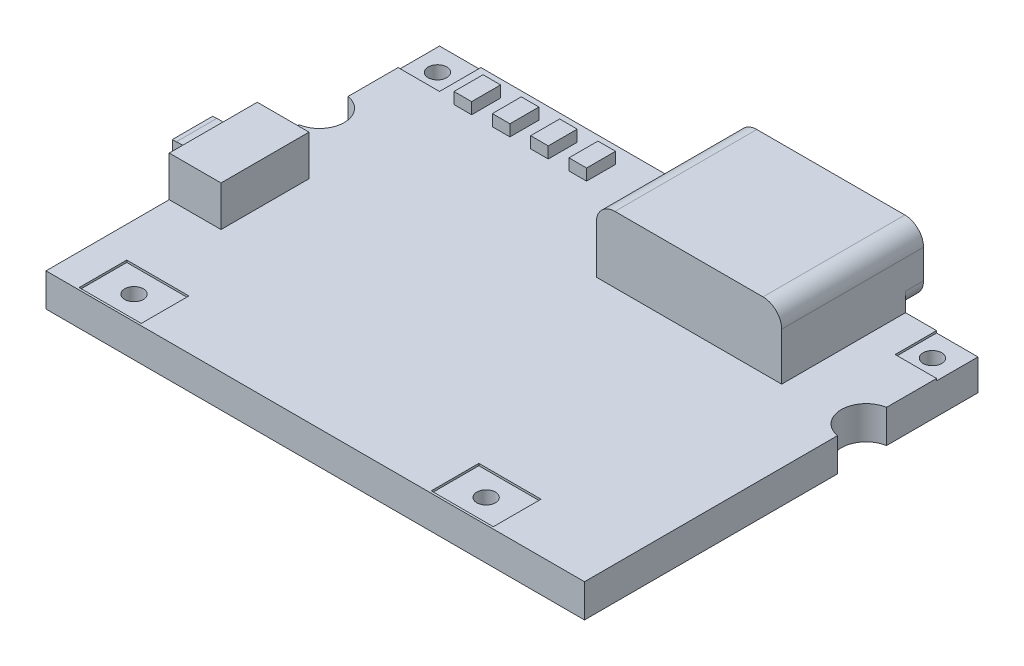
from build123d import *

# Parameters (mm, degrees)
SKETCH1_W           = 26
SKETCH1_H           = 19
BOSS_EXTRUDE1_DEPTH = 1.6
SKETCH2_W           = 8.95
SKETCH2_H           = 6.85
BOSS_EXTRUDE2_DEPTH = 3.2
SKETCH3_R           = 0.45
CUT_EXTRUDE1_DEPTH  = 17.934488478
SKETCH4_R           = 1.2
CUT_EXTRUDE2_DEPTH  = 17.934488478
SKETCH5_R           = 0.45
CUT_EXTRUDE3_DEPTH  = 17.934488478
SKETCH6_W           = 2
SKETCH6_H           = 2
SKETCH6_W_2         = 3
SKETCH6_H_2         = 2.3
CUT_EXTRUDE4_DEPTH  = 0.1
FILLET1_R           = 0.9
SKETCH8_W           = 2.5
SKETCH8_H           = 4.25
BOSS_EXTRUDE3_DEPTH = 1.95
SKETCH9_W           = 1.95
SKETCH9_H           = 0.95
BOSS_EXTRUDE4_DEPTH = 1
SKETCH10_W          = 0.85
SKETCH10_H          = 1.4
BOSS_EXTRUDE5_DEPTH = 0.55
LPATTERN1_COUNT     = 4
LPATTERN1_PITCH     = 1.85
SKETCH11_W          = 0.2
SKETCH11_H          = 1.95
CUT_EXTRUDE5_DEPTH  = 0.01


with BuildPart() as part:
    # Sketch1 → Boss-Extrude1 (new body)
    with BuildSketch(Plane(origin=(0, 0, 0), x_dir=(1, 0, 0), z_dir=(0, 1, 0))):
        Rectangle(SKETCH1_W, SKETCH1_H)
    extrude(amount=BOSS_EXTRUDE1_DEPTH)

    # Sketch2 → Boss-Extrude2 (add)
    with BuildSketch(Plane(origin=(0, 1.6, 0), x_dir=(1, 0, 0), z_dir=(0, 1, 0))):
        with Locations((5.025, 6.945)):
            Rectangle(SKETCH2_W, SKETCH2_H)
    extrude(amount=BOSS_EXTRUDE2_DEPTH)

    # Sketch3 → Cut-Extrude1 (cut, through all)
    with BuildSketch(Plane(origin=(0, 1.6, 0), x_dir=(1, 0, 0), z_dir=(0, 1, 0))):
        with Locations((-10, -8.25)):
            Circle(SKETCH3_R)
        with Locations((7, -8.25)):
            Circle(SKETCH3_R)
    extrude(amount=-CUT_EXTRUDE1_DEPTH, mode=Mode.SUBTRACT)

    # Sketch4 → Cut-Extrude2 (cut, through all)
    with BuildSketch(Plane(origin=(0, 1.6, 0), x_dir=(1, 0, 0), z_dir=(0, 1, 0))):
        with Locations((-13.2, 3.9)):
            Circle(SKETCH4_R)
        with Locations((13.2, 3.9)):
            Circle(SKETCH4_R)
    extrude(amount=-CUT_EXTRUDE2_DEPTH, mode=Mode.SUBTRACT)

    # Sketch5 → Cut-Extrude3 (cut, through all)
    with BuildSketch(Plane(origin=(0, 1.6, 0), x_dir=(1, 0, 0), z_dir=(0, 1, 0))):
        with Locations((-11.95, 8.35)):
            Circle(SKETCH5_R)
        with Locations((11.95, 8.35)):
            Circle(SKETCH5_R)
    extrude(amount=-CUT_EXTRUDE3_DEPTH, mode=Mode.SUBTRACT)

    # Sketch6 → Cut-Extrude4 (cut)
    with BuildSketch(Plane(origin=(0, 1.6, 0), x_dir=(1, 0, 0), z_dir=(0, 1, 0))):
        with Locations((-12, 8.5)):
            Rectangle(SKETCH6_W, SKETCH6_H)
        with Locations((12, 8.5)):
            Rectangle(SKETCH6_W, SKETCH6_H)
        with Locations((-10, -8.25)):
            Rectangle(SKETCH6_W_2, SKETCH6_H_2)
        with Locations((7, -8.25)):
            Rectangle(SKETCH6_W_2, SKETCH6_H_2)
    extrude(amount=-CUT_EXTRUDE4_DEPTH, mode=Mode.SUBTRACT)

    # Fillet1
    fillet1_edges = [part.edges().sort_by_distance(p)[0] for p in [
        (0.55, 1.6, -9.935),
        (0.55, 4.8, -6.945),
        (9.5, 4.8, -6.945),
        (9.5, 1.6, -9.935),
    ]]
    fillet(fillet1_edges, radius=FILLET1_R)

    # Sketch8 → Boss-Extrude3 (add)
    with BuildSketch(Plane(origin=(0, 1.6, 0), x_dir=(1, 0, 0), z_dir=(0, 1, 0))):
        with Locations((-11.75, -1.425)):
            Rectangle(SKETCH8_W, SKETCH8_H)
    extrude(amount=BOSS_EXTRUDE3_DEPTH)

    # Sketch9 → Boss-Extrude4 (add)
    with BuildSketch(Plane.ZY.offset(13)):
        with Locations((1.425, 2.575)):
            Rectangle(SKETCH9_W, SKETCH9_H)
    extrude(amount=BOSS_EXTRUDE4_DEPTH)

    # Sketch10 → Boss-Extrude5 (add)
    with BuildSketch(Plane(origin=(0, 1.6, 0), x_dir=(1, 0, 0), z_dir=(0, 1, 0))):
        with Locations((-9.675, 8)):
            Rectangle(SKETCH10_W, SKETCH10_H)
    boss_extrude5 = extrude(amount=BOSS_EXTRUDE5_DEPTH)

    # LPattern1: Boss-Extrude5 ×4
    with Locations(*[(i * LPATTERN1_PITCH, 0, 0) for i in range(1, LPATTERN1_COUNT)]):
        add(boss_extrude5)

    # Sketch11 → Cut-Extrude5 (cut)
    with BuildSketch(Plane(origin=(0, 3.05, 0), x_dir=(1, 0, 0), z_dir=(0, 1, 0))):
        with Locations((-13.9, -1.425)):
            Rectangle(SKETCH11_W, SKETCH11_H)
    extrude(amount=-CUT_EXTRUDE5_DEPTH, mode=Mode.SUBTRACT)


solid = part.part
